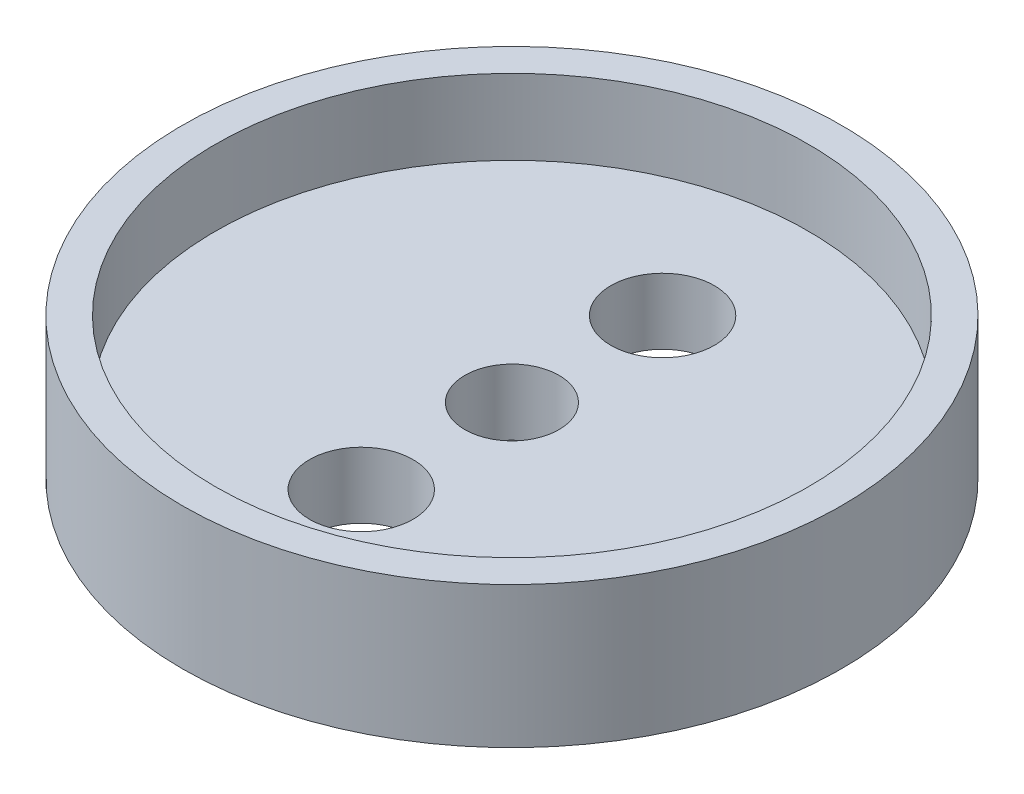
from build123d import *

# Parameters (mm, degrees)
SKETCH4_R        = 17.5
SKETCH4_R_2      = 2.75
SKETCH4_R_3      = 2.5
LIDBASE_DEPTH    = 7.5
SKETCH5_R        = 15.75
LIDGROOVES_DEPTH = 4


with BuildPart() as part:
    # Sketch4 → LidBase (new body)
    with BuildSketch(Plane(origin=(0, 0, 0), x_dir=(1, 0, 0), z_dir=(0, 1, 0))):
        Circle(SKETCH4_R)
        with Locations((0, -8)):
            Circle(SKETCH4_R_2, mode=Mode.SUBTRACT)
        with Locations((0, 8)):
            Circle(SKETCH4_R_2, mode=Mode.SUBTRACT)
        Circle(SKETCH4_R_3, mode=Mode.SUBTRACT)
    extrude(amount=LIDBASE_DEPTH)

    # Sketch5 → LidGrooves (cut)
    with BuildSketch(Plane(origin=(0, 7.5, 0), x_dir=(1, 0, 0), z_dir=(0, 1, 0))):
        Circle(SKETCH5_R)
    extrude(amount=-LIDGROOVES_DEPTH, mode=Mode.SUBTRACT)


solid = part.part
